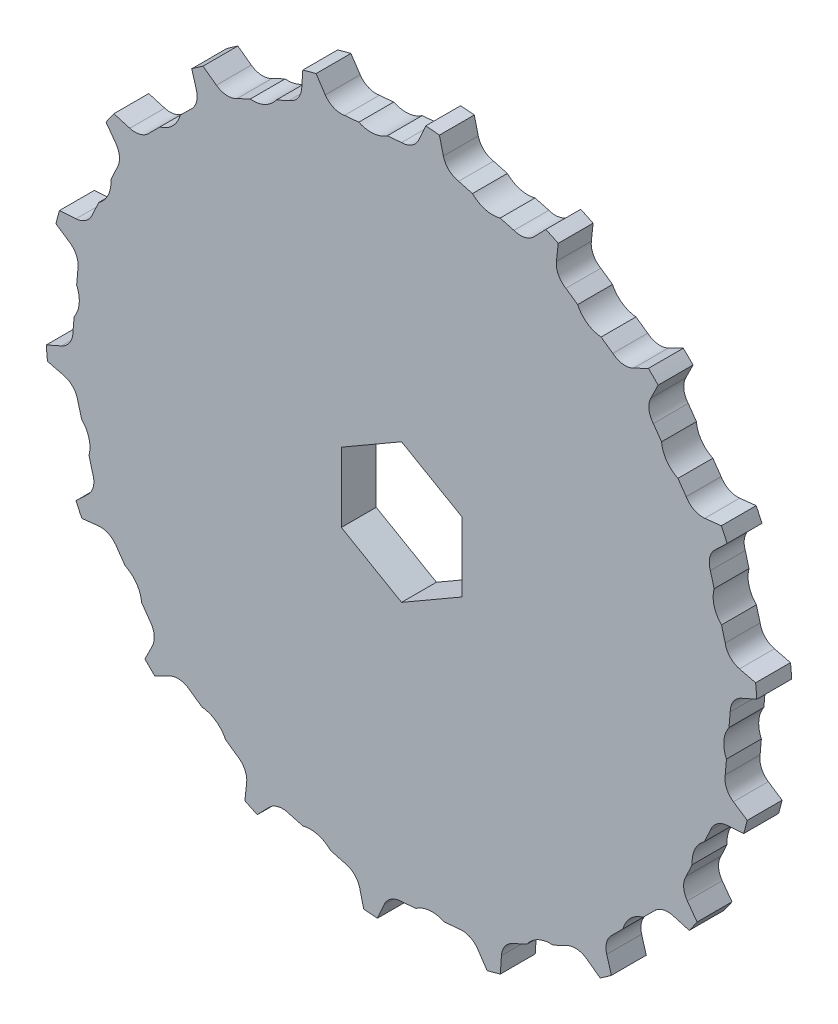
from build123d import *

# Parameters (mm, degrees)
BOSS_EXTRUDE1_DEPTH                 = 7.3
SKETCH2_R                           = 12.5
BOSS_EXTRUDE2_DEPTH                 = 40
CUT_EXTRUDE2_DEPTH                  = 10
SKETCH9_R                           = 100
SKETCH9_R_2                         = 74.5
CUT_EXTRUDE5_DEPTH                  = 10
FILLET1_R                           = 30
SKETCH3_R                           = 5
CUT_EXTRUDE1_DEPTH                  = 48.3
F_1_0MM_DOWEL_HOLE1_D               = 2.8
F_1_0MM_DOWEL_HOLE1_DEPTH           = 33.158795133
F_1_0MM_DOWEL_HOLE1_TIP             = 0.841204867
F_1_0MM_DOWEL_HOLE1_ON_FACE_2_D     = 2.8
F_1_0MM_DOWEL_HOLE1_ON_FACE_2_DEPTH = 33.158795133
F_1_0MM_DOWEL_HOLE1_ON_FACE_2_TIP   = 0.841204867
CIRPATTERN1_COUNT                   = 18
SKETCH6_W                           = 154.233328221
SKETCH6_H                           = 44.757292759
CUT_EXTRUDE3_DEPTH                  = 75.327856081
CUT_EXTRUDE3_DEPTH_BACK             = 75.327856081
CUT_EXTRUDE4_DEPTH                  = 1
CUT_EXTRUDE4_DEPTH_BACK             = 8.3


with BuildPart() as part:
    # Sketch1 → Boss-Extrude1 (new body)
    with BuildSketch(Plane.XY):
        with BuildLine():
            ThreePointArc((3.659616426, 71.150315011), (0, 68.765), (-3.659616426, 71.150315011))
            Line((-3.659616426, 71.150315011), (-5.674070045, 75.715990423))
            ThreePointArc((-5.674070045, 75.715990423), (-6.676129894, 76.308513874), (-7.560075586, 75.550986319))
            Line((-7.560075586, 75.550986319), (-8.751103913, 70.704867575))
            ThreePointArc((-8.751103913, 70.704867575), (-11.940916937, 67.720305136), (-15.959141171, 69.433896128))
            Line((-15.959141171, 69.433896128), (-18.735811929, 73.580402472))
            ThreePointArc((-18.735811929, 73.580402472), (-19.825538855, 73.989918294), (-20.564512145, 73.090403726))
            Line((-20.564512145, 73.090403726), (-20.895926387, 68.111088517))
            ThreePointArc((-20.895926387, 68.111088517), (-23.519015156, 64.617963068), (-27.773755488, 65.607763448))
            Line((-27.773755488, 65.607763448), (-31.228275648, 69.209111226))
            ThreePointArc((-31.228275648, 69.209111226), (-32.372558849, 69.423176487), (-32.94410641, 68.409006202))
            Line((-32.94410641, 68.409006202), (-32.405836712, 63.4477885))
            ThreePointArc((-32.405836712, 63.4477885), (-34.3825, 59.552236891), (-38.744478298, 59.788172074))
            Line((-38.744478298, 59.788172074), (-42.771884014, 62.734936156))
            ThreePointArc((-42.771884014, 62.734936156), (-43.935955024, 62.747046593), (-44.322710671, 61.64903564))
            Line((-44.322710671, 61.64903564), (-42.931112087, 56.856659535))
            ThreePointArc((-42.931112087, 56.856659535), (-44.20128998, 52.677046131), (-48.537969741, 52.151947345))
            Line((-48.537969741, 52.151947345), (-53.015890327, 54.354591797))
            ThreePointArc((-53.015890327, 54.354591797), (-54.164379439, 54.164379439), (-54.354591797, 53.015890327))
            Line((-54.354591797, 53.015890327), (-52.151947345, 48.537969741))
            ThreePointArc((-52.151947345, 48.537969741), (-52.677046131, 44.20128998), (-56.856659535, 42.931112087))
            Line((-56.856659535, 42.931112087), (-61.64903564, 44.322710671))
            ThreePointArc((-61.64903564, 44.322710671), (-62.747046593, 43.935955024), (-62.734936156, 42.771884014))
            Line((-62.734936156, 42.771884014), (-59.788172074, 38.744478298))
            ThreePointArc((-59.788172074, 38.744478298), (-59.552236891, 34.3825), (-63.4477885, 32.405836712))
            Line((-63.4477885, 32.405836712), (-68.409006202, 32.94410641))
            ThreePointArc((-68.409006202, 32.94410641), (-69.423176487, 32.372558849), (-69.209111226, 31.228275648))
            Line((-69.209111226, 31.228275648), (-65.607763448, 27.773755488))
            ThreePointArc((-65.607763448, 27.773755488), (-64.617963068, 23.519015156), (-68.111088517, 20.895926387))
            Line((-68.111088517, 20.895926387), (-73.090403726, 20.564512145))
            ThreePointArc((-73.090403726, 20.564512145), (-73.989918294, 19.825538855), (-73.580402472, 18.735811929))
            Line((-73.580402472, 18.735811929), (-69.433896128, 15.959141171))
            ThreePointArc((-69.433896128, 15.959141171), (-67.720305136, 11.940916937), (-70.704867575, 8.751103913))
            Line((-70.704867575, 8.751103913), (-75.550986319, 7.560075586))
            ThreePointArc((-75.550986319, 7.560075586), (-76.308513874, 6.676129894), (-75.715990423, 5.674070045))
            Line((-75.715990423, 5.674070045), (-71.150315011, 3.659616426))
            ThreePointArc((-71.150315011, 3.659616426), (-68.765, 0), (-71.150315011, -3.659616426))
            Line((-71.150315011, -3.659616426), (-75.715990423, -5.674070045))
            ThreePointArc((-75.715990423, -5.674070045), (-76.308513874, -6.676129894), (-75.550986319, -7.560075586))
            Line((-75.550986319, -7.560075586), (-70.704867575, -8.751103913))
            ThreePointArc((-70.704867575, -8.751103913), (-67.720305136, -11.940916937), (-69.433896128, -15.959141171))
            Line((-69.433896128, -15.959141171), (-73.580402472, -18.735811929))
            ThreePointArc((-73.580402472, -18.735811929), (-73.989918294, -19.825538855), (-73.090403726, -20.564512145))
            Line((-73.090403726, -20.564512145), (-68.111088517, -20.895926387))
            ThreePointArc((-68.111088517, -20.895926387), (-64.617963068, -23.519015156), (-65.607763448, -27.773755488))
            Line((-65.607763448, -27.773755488), (-69.209111226, -31.228275648))
            ThreePointArc((-69.209111226, -31.228275648), (-69.423176487, -32.372558849), (-68.409006202, -32.94410641))
            Line((-68.409006202, -32.94410641), (-63.4477885, -32.405836712))
            ThreePointArc((-63.4477885, -32.405836712), (-59.552236891, -34.3825), (-59.788172074, -38.744478298))
            Line((-59.788172074, -38.744478298), (-62.734936156, -42.771884014))
            ThreePointArc((-62.734936156, -42.771884014), (-62.747046593, -43.935955024), (-61.64903564, -44.322710671))
            Line((-61.64903564, -44.322710671), (-56.856659535, -42.931112087))
            ThreePointArc((-56.856659535, -42.931112087), (-52.677046131, -44.20128998), (-52.151947345, -48.537969741))
            Line((-52.151947345, -48.537969741), (-54.354591797, -53.015890327))
            ThreePointArc((-54.354591797, -53.015890327), (-54.164379439, -54.164379439), (-53.015890327, -54.354591797))
            Line((-53.015890327, -54.354591797), (-48.537969741, -52.151947345))
            ThreePointArc((-48.537969741, -52.151947345), (-44.20128998, -52.677046131), (-42.931112087, -56.856659535))
            Line((-42.931112087, -56.856659535), (-44.322710671, -61.64903564))
            ThreePointArc((-44.322710671, -61.64903564), (-43.935955024, -62.747046593), (-42.771884014, -62.734936156))
            Line((-42.771884014, -62.734936156), (-38.744478298, -59.788172074))
            ThreePointArc((-38.744478298, -59.788172074), (-34.3825, -59.552236891), (-32.405836712, -63.4477885))
            Line((-32.405836712, -63.4477885), (-32.94410641, -68.409006202))
            ThreePointArc((-32.94410641, -68.409006202), (-32.372558849, -69.423176487), (-31.228275648, -69.209111226))
            Line((-31.228275648, -69.209111226), (-27.773755488, -65.607763448))
            ThreePointArc((-27.773755488, -65.607763448), (-23.519015156, -64.617963068), (-20.895926387, -68.111088517))
            Line((-20.895926387, -68.111088517), (-20.564512145, -73.090403726))
            ThreePointArc((-20.564512145, -73.090403726), (-19.825538855, -73.989918294), (-18.735811929, -73.580402472))
            Line((-18.735811929, -73.580402472), (-15.959141171, -69.433896128))
            ThreePointArc((-15.959141171, -69.433896128), (-11.940916937, -67.720305136), (-8.751103913, -70.704867575))
            Line((-8.751103913, -70.704867575), (-7.560075586, -75.550986319))
            ThreePointArc((-7.560075586, -75.550986319), (-6.676129894, -76.308513874), (-5.674070045, -75.715990423))
            Line((-5.674070045, -75.715990423), (-3.659616426, -71.150315011))
            ThreePointArc((-3.659616426, -71.150315011), (0, -68.765), (3.659616426, -71.150315011))
            Line((3.659616426, -71.150315011), (5.674070045, -75.715990423))
            ThreePointArc((5.674070045, -75.715990423), (6.676129894, -76.308513874), (7.560075586, -75.550986319))
            Line((7.560075586, -75.550986319), (8.751103913, -70.704867575))
            ThreePointArc((8.751103913, -70.704867575), (11.940916937, -67.720305136), (15.959141171, -69.433896128))
            Line((15.959141171, -69.433896128), (18.735811929, -73.580402472))
            ThreePointArc((18.735811929, -73.580402472), (19.825538855, -73.989918294), (20.564512145, -73.090403726))
            Line((20.564512145, -73.090403726), (20.895926387, -68.111088517))
            ThreePointArc((20.895926387, -68.111088517), (23.519015156, -64.617963068), (27.773755488, -65.607763448))
            Line((27.773755488, -65.607763448), (31.228275648, -69.209111226))
            ThreePointArc((31.228275648, -69.209111226), (32.372558849, -69.423176487), (32.94410641, -68.409006202))
            Line((32.94410641, -68.409006202), (32.405836712, -63.4477885))
            ThreePointArc((32.405836712, -63.4477885), (34.3825, -59.552236891), (38.744478298, -59.788172074))
            Line((38.744478298, -59.788172074), (42.771884014, -62.734936156))
            ThreePointArc((42.771884014, -62.734936156), (43.935955024, -62.747046593), (44.322710671, -61.64903564))
            Line((44.322710671, -61.64903564), (42.931112087, -56.856659535))
            ThreePointArc((42.931112087, -56.856659535), (44.20128998, -52.677046131), (48.537969741, -52.151947345))
            Line((48.537969741, -52.151947345), (53.015890327, -54.354591797))
            ThreePointArc((53.015890327, -54.354591797), (54.164379439, -54.164379439), (54.354591797, -53.015890327))
            Line((54.354591797, -53.015890327), (52.151947345, -48.537969741))
            ThreePointArc((52.151947345, -48.537969741), (52.677046131, -44.20128998), (56.856659535, -42.931112087))
            Line((56.856659535, -42.931112087), (61.64903564, -44.322710671))
            ThreePointArc((61.64903564, -44.322710671), (62.747046593, -43.935955024), (62.734936156, -42.771884014))
            Line((62.734936156, -42.771884014), (59.788172074, -38.744478298))
            ThreePointArc((59.788172074, -38.744478298), (59.552236891, -34.3825), (63.4477885, -32.405836712))
            Line((63.4477885, -32.405836712), (68.409006202, -32.94410641))
            ThreePointArc((68.409006202, -32.94410641), (69.423176487, -32.372558849), (69.209111226, -31.228275648))
            Line((69.209111226, -31.228275648), (65.607763448, -27.773755488))
            ThreePointArc((65.607763448, -27.773755488), (64.617963068, -23.519015156), (68.111088517, -20.895926387))
            Line((68.111088517, -20.895926387), (73.090403726, -20.564512145))
            ThreePointArc((73.090403726, -20.564512145), (73.989918294, -19.825538855), (73.580402472, -18.735811929))
            Line((73.580402472, -18.735811929), (69.433896128, -15.959141171))
            ThreePointArc((69.433896128, -15.959141171), (67.720305136, -11.940916937), (70.704867575, -8.751103913))
            Line((70.704867575, -8.751103913), (75.550986319, -7.560075586))
            ThreePointArc((75.550986319, -7.560075586), (76.308513874, -6.676129894), (75.715990423, -5.674070045))
            Line((75.715990423, -5.674070045), (71.150315011, -3.659616426))
            ThreePointArc((71.150315011, -3.659616426), (68.765, 0), (71.150315011, 3.659616426))
            Line((71.150315011, 3.659616426), (75.715990423, 5.674070045))
            ThreePointArc((75.715990423, 5.674070045), (76.308513874, 6.676129894), (75.550986319, 7.560075586))
            Line((75.550986319, 7.560075586), (70.704867575, 8.751103913))
            ThreePointArc((70.704867575, 8.751103913), (67.720305136, 11.940916937), (69.433896128, 15.959141171))
            Line((69.433896128, 15.959141171), (73.580402472, 18.735811929))
            ThreePointArc((73.580402472, 18.735811929), (73.989918294, 19.825538855), (73.090403726, 20.564512145))
            Line((73.090403726, 20.564512145), (68.111088517, 20.895926387))
            ThreePointArc((68.111088517, 20.895926387), (64.617963068, 23.519015156), (65.607763448, 27.773755488))
            Line((65.607763448, 27.773755488), (69.209111226, 31.228275648))
            ThreePointArc((69.209111226, 31.228275648), (69.423176487, 32.372558849), (68.409006202, 32.94410641))
            Line((68.409006202, 32.94410641), (63.4477885, 32.405836712))
            ThreePointArc((63.4477885, 32.405836712), (59.552236891, 34.3825), (59.788172074, 38.744478298))
            Line((59.788172074, 38.744478298), (62.734936156, 42.771884014))
            ThreePointArc((62.734936156, 42.771884014), (62.747046593, 43.935955024), (61.64903564, 44.322710671))
            Line((61.64903564, 44.322710671), (56.856659535, 42.931112087))
            ThreePointArc((56.856659535, 42.931112087), (52.677046131, 44.20128998), (52.151947345, 48.537969741))
            Line((52.151947345, 48.537969741), (54.354591797, 53.015890327))
            ThreePointArc((54.354591797, 53.015890327), (54.164379439, 54.164379439), (53.015890327, 54.354591797))
            Line((53.015890327, 54.354591797), (48.537969741, 52.151947345))
            ThreePointArc((48.537969741, 52.151947345), (44.20128998, 52.677046131), (42.931112087, 56.856659535))
            Line((42.931112087, 56.856659535), (44.322710671, 61.64903564))
            ThreePointArc((44.322710671, 61.64903564), (43.935955024, 62.747046593), (42.771884014, 62.734936156))
            Line((42.771884014, 62.734936156), (38.744478298, 59.788172074))
            ThreePointArc((38.744478298, 59.788172074), (34.3825, 59.552236891), (32.405836712, 63.4477885))
            Line((32.405836712, 63.4477885), (32.94410641, 68.409006202))
            ThreePointArc((32.94410641, 68.409006202), (32.372558849, 69.423176487), (31.228275648, 69.209111226))
            Line((31.228275648, 69.209111226), (27.773755488, 65.607763448))
            ThreePointArc((27.773755488, 65.607763448), (23.519015156, 64.617963068), (20.895926387, 68.111088517))
            Line((20.895926387, 68.111088517), (20.564512145, 73.090403726))
            ThreePointArc((20.564512145, 73.090403726), (19.825538855, 73.989918294), (18.735811929, 73.580402472))
            Line((18.735811929, 73.580402472), (15.959141171, 69.433896128))
            ThreePointArc((15.959141171, 69.433896128), (11.940916937, 67.720305136), (8.751103913, 70.704867575))
            Line((8.751103913, 70.704867575), (7.560075586, 75.550986319))
            ThreePointArc((7.560075586, 75.550986319), (6.676129894, 76.308513874), (5.674070045, 75.715990423))
            Line((5.674070045, 75.715990423), (3.659616426, 71.150315011))
        make_face()
    extrude(amount=BOSS_EXTRUDE1_DEPTH)

    # Sketch2 → Boss-Extrude2 (add)
    with BuildSketch(Plane.XY.offset(7.3)):
        Circle(SKETCH2_R)
    extrude(amount=BOSS_EXTRUDE2_DEPTH)

    # Sketch5 → Cut-Extrude2 (cut)
    with BuildSketch(Plane(origin=(0, 0, 0), x_dir=(-1, 0, 0), z_dir=(0, 0, -1))):
        with BuildLine():
            Line((0, 68.765), (2.988584094, 68.503532772))
            ThreePointArc((2.988584094, 68.503532772), (5.900736948, 67.445731938), (8.952332843, 67.981772364))
            Line((8.952332843, 67.981772364), (11.940916937, 67.720305136))
            Line((11.940916937, 67.720305136), (12.646588363, 75.786166442))
            Line((12.646588363, 75.786166442), (0.705671426, 76.830861306))
            Line((0.705671426, 76.830861306), (0, 68.765))
        make_face()
    cut_extrude2 = extrude(amount=-CUT_EXTRUDE2_DEPTH, mode=Mode.SUBTRACT)

    # Sketch9 → Cut-Extrude5 (cut)
    with BuildSketch(Plane(origin=(0, 0, 0), x_dir=(-1, 0, 0), z_dir=(0, 0, -1))):
        Circle(SKETCH9_R)
        Circle(SKETCH9_R_2, mode=Mode.SUBTRACT)
    extrude(amount=-CUT_EXTRUDE5_DEPTH, mode=Mode.SUBTRACT)

    # Fillet1
    fillet1_edges = [part.edges().sort_by_distance(p)[0] for p in [
        (-12.5, 0, 7.3),
    ]]
    fillet(fillet1_edges, radius=FILLET1_R)

    # Sketch3 → Cut-Extrude1 (cut, through all)
    with BuildSketch(Plane.XY.offset(47.3)):
        Circle(SKETCH3_R)
    extrude(amount=-CUT_EXTRUDE1_DEPTH, mode=Mode.SUBTRACT)

    # Ø1.0mm Dowel Hole1
    with Locations(Plane(origin=(-6.81763654, -10.477109907, 42.020116055), x_dir=(-0.838168793, 0.545410923, 0), z_dir=(-0.545410923, -0.838168793, 0))):
        with Locations((0, 0)):
            Hole(F_1_0MM_DOWEL_HOLE1_D / 2, depth=F_1_0MM_DOWEL_HOLE1_DEPTH)
            with Locations((0, 0, -(F_1_0MM_DOWEL_HOLE1_DEPTH + F_1_0MM_DOWEL_HOLE1_TIP / 2))):  # 118° drill point
                Cone(0, F_1_0MM_DOWEL_HOLE1_D / 2, F_1_0MM_DOWEL_HOLE1_TIP, mode=Mode.SUBTRACT)

    # Ø1.0mm Dowel Hole1 on face 2
    with Locations(Plane(origin=(-11.068439798, 5.808583342, 41.658255729), x_dir=(-0.464687004, -0.885475007, 0), z_dir=(-0.885475007, 0.464687004, 0))):
        with Locations((0, 0)):
            Hole(F_1_0MM_DOWEL_HOLE1_ON_FACE_2_D / 2, depth=F_1_0MM_DOWEL_HOLE1_ON_FACE_2_DEPTH)
            with Locations((0, 0, -(F_1_0MM_DOWEL_HOLE1_ON_FACE_2_DEPTH + F_1_0MM_DOWEL_HOLE1_ON_FACE_2_TIP / 2))):  # 118° drill point
                Cone(0, F_1_0MM_DOWEL_HOLE1_ON_FACE_2_D / 2, F_1_0MM_DOWEL_HOLE1_ON_FACE_2_TIP, mode=Mode.SUBTRACT)

    # CirPattern1: Cut-Extrude2 ×18 about axis
    cirpattern1_axis = Axis((0, 0, 0), (0, 0, 1))
    for i in range(1, CIRPATTERN1_COUNT):
        add(cut_extrude2.rotate(cirpattern1_axis, i * 360 / CIRPATTERN1_COUNT), mode=Mode.SUBTRACT)

    # Sketch6 → Cut-Extrude3 (cut, two sides)
    with BuildSketch(Plane(origin=(0, 0, 0), x_dir=(1, 0, 0), z_dir=(0, 1, 0))) as cut_extrude3_sk:
        with Locations((2.788808029, -29.67864638)):
            Rectangle(SKETCH6_W, SKETCH6_H)
    extrude(amount=CUT_EXTRUDE3_DEPTH, mode=Mode.SUBTRACT)
    extrude(cut_extrude3_sk.sketch, amount=-CUT_EXTRUDE3_DEPTH_BACK, mode=Mode.SUBTRACT)

    # Sketch7 → Cut-Extrude4 (cut, two sides)
    with BuildSketch(Plane(origin=(0, 0, 0), x_dir=(-1, 0, 0), z_dir=(0, 0, -1))) as cut_extrude4_sk:
        Polygon((12.6, -7.274613392), (12.6, 7.274613392), (0, 14.549226784), (-12.6, 7.274613392), (-12.6, -7.274613392), (0, -14.549226784), align=None)
    extrude(amount=CUT_EXTRUDE4_DEPTH, mode=Mode.SUBTRACT)
    extrude(cut_extrude4_sk.sketch, amount=-CUT_EXTRUDE4_DEPTH_BACK, mode=Mode.SUBTRACT)


solid = part.part
